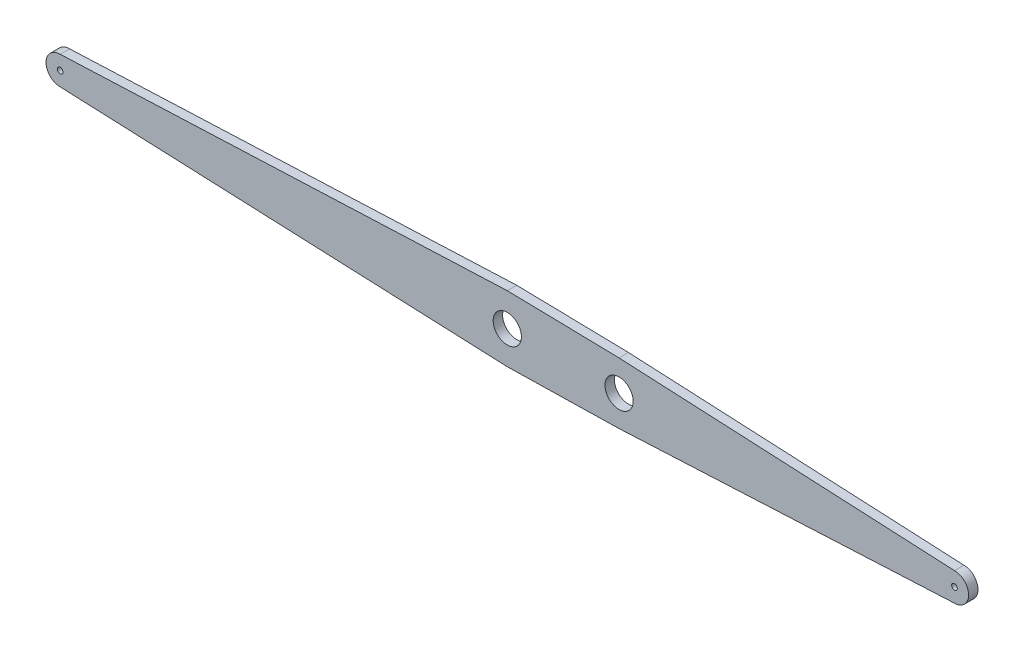
from build123d import *

# Parameters (mm, degrees)
SKIZZE1_R                       = 30
SKIZZE1_R_2                     = 6
AUFSATZ_LINEAR_AUSTRAGEN1_DEPTH = 20


with BuildPart() as part:
    # Skizze1 → Aufsatz-Linear austragen1 (new body)
    with BuildSketch(Plane.XY):
        with BuildLine():
            Line((-950, 70), (-712.5, 65))
            Line((-712.5, 65), (0, 30))
            ThreePointArc((0, 30), (30, 0), (0, -30))
            Line((0, -30), (-712.5, -65))
            Line((-712.5, -65), (-950, -70))
            Line((-950, -70), (-1900, -30))
            ThreePointArc((-1900, -30), (-1930, 0), (-1900, 30))
            Line((-1900, 30), (-950, 70))
        make_face()
        with Locations((-950, 0)):
            Circle(SKIZZE1_R, mode=Mode.SUBTRACT)
        with Locations((-712.5, 0)):
            Circle(SKIZZE1_R, mode=Mode.SUBTRACT)
        with Locations((-1900, 0)):
            Circle(SKIZZE1_R_2, mode=Mode.SUBTRACT)
        Circle(SKIZZE1_R_2, mode=Mode.SUBTRACT)
    extrude(amount=AUFSATZ_LINEAR_AUSTRAGEN1_DEPTH)


solid = part.part
